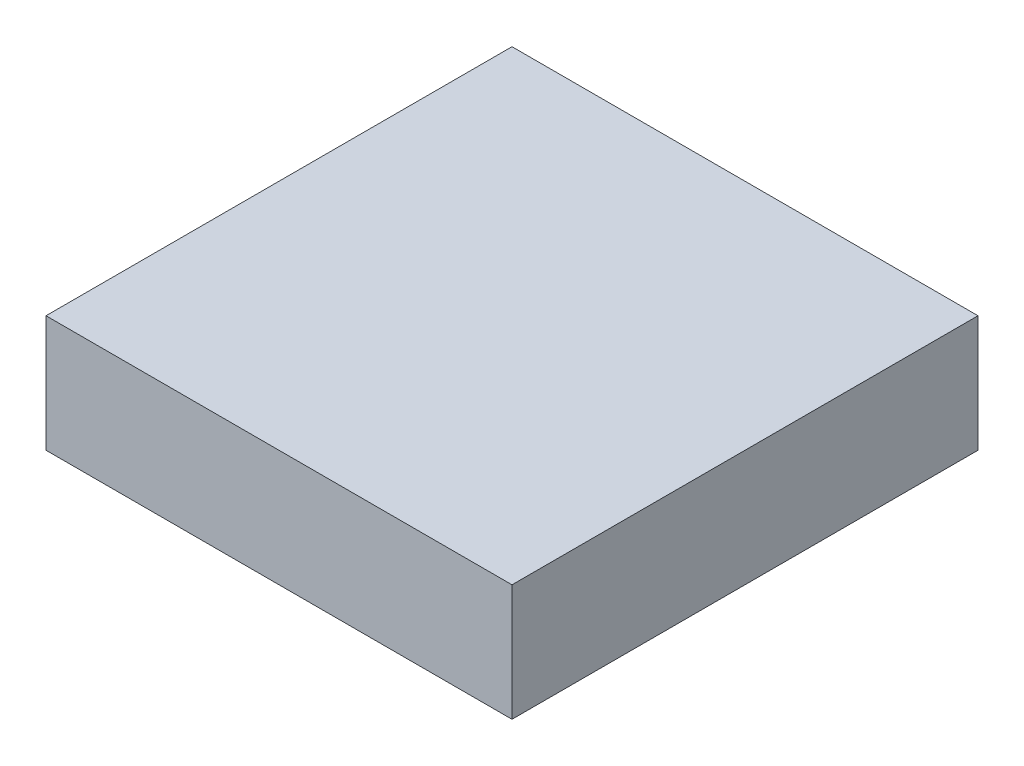
from build123d import *

# Parameters (mm, degrees)
SKETCH1_W           = 4
SKETCH1_H           = 4
BOSS_EXTRUDE1_DEPTH = 1


with BuildPart() as part:
    # Sketch1 → Boss-Extrude1 (new body)
    with BuildSketch(Plane(origin=(0, 0, 0), x_dir=(1, 0, 0), z_dir=(0, 1, 0))):
        with Locations((-1.040932412, -0.170241609)):
            Rectangle(SKETCH1_W, SKETCH1_H)
    extrude(amount=BOSS_EXTRUDE1_DEPTH)


solid = part.part
